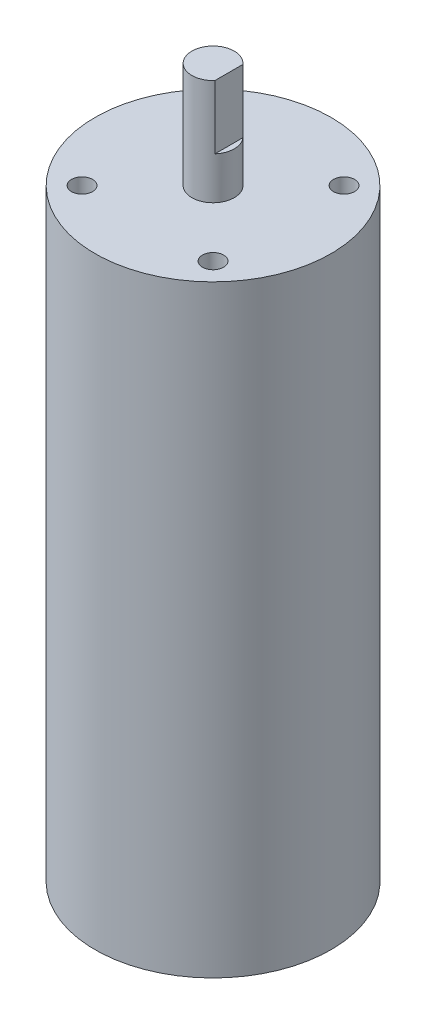
from build123d import *

# Parameters (mm, degrees)
SKETCH3_W               = 1
SKETCH3_H               = 12
CUT_EXTRUDE1_DEPTH      = 23.3
CUT_EXTRUDE1_DEPTH_BACK = 23.3
SKETCH4_R               = 2
CUT_EXTRUDE2_DEPTH      = 10


with BuildPart() as part:
    # Sketch2 → Revolve1 (revolve)
    with BuildSketch(Plane.XY, mode=Mode.PRIVATE) as revolve1_sk:
        Polygon((0, 0), (22.3, 0), (22.3, 113.9), (4, 113.9), (4, 133.9), (0, 133.9), align=None)
    revolve(revolve1_sk.sketch.rotate(Axis((0, 0, 0), (0, 1, 0)), 90), axis=Axis((0, 0, 0), (0, 1, 0)))  # turned: the seam where the file's is

    # Sketch3 → Cut-Extrude1 (cut, two sides)
    with BuildSketch(Plane.XY) as cut_extrude1_sk:
        with Locations((3.5, 127.9)):
            Rectangle(SKETCH3_W, SKETCH3_H)
    extrude(amount=CUT_EXTRUDE1_DEPTH, mode=Mode.SUBTRACT)
    extrude(cut_extrude1_sk.sketch, amount=-CUT_EXTRUDE1_DEPTH_BACK, mode=Mode.SUBTRACT)

    # Sketch4 → Cut-Extrude2 (cut)
    with BuildSketch(Plane(origin=(0, 113.9, 0), x_dir=(1, 0, 0), z_dir=(0, 1, 0))):
        with Locations(Location((-12.374368671, 12.374368671, 0), (0, 0, 270))):  # turned: the seam where the file's is
            Circle(SKETCH4_R)
        with Locations(Location((12.374368671, 12.374368671, 0), (0, 0, 270))):  # turned: the seam where the file's is
            Circle(SKETCH4_R)
        with Locations(Location((12.374368671, -12.374368671, 0), (0, 0, 270))):  # turned: the seam where the file's is
            Circle(SKETCH4_R)
        with Locations(Location((-12.374368671, -12.374368671, 0), (0, 0, 270))):  # turned: the seam where the file's is
            Circle(SKETCH4_R)
    extrude(amount=-CUT_EXTRUDE2_DEPTH, mode=Mode.SUBTRACT)


solid = part.part
